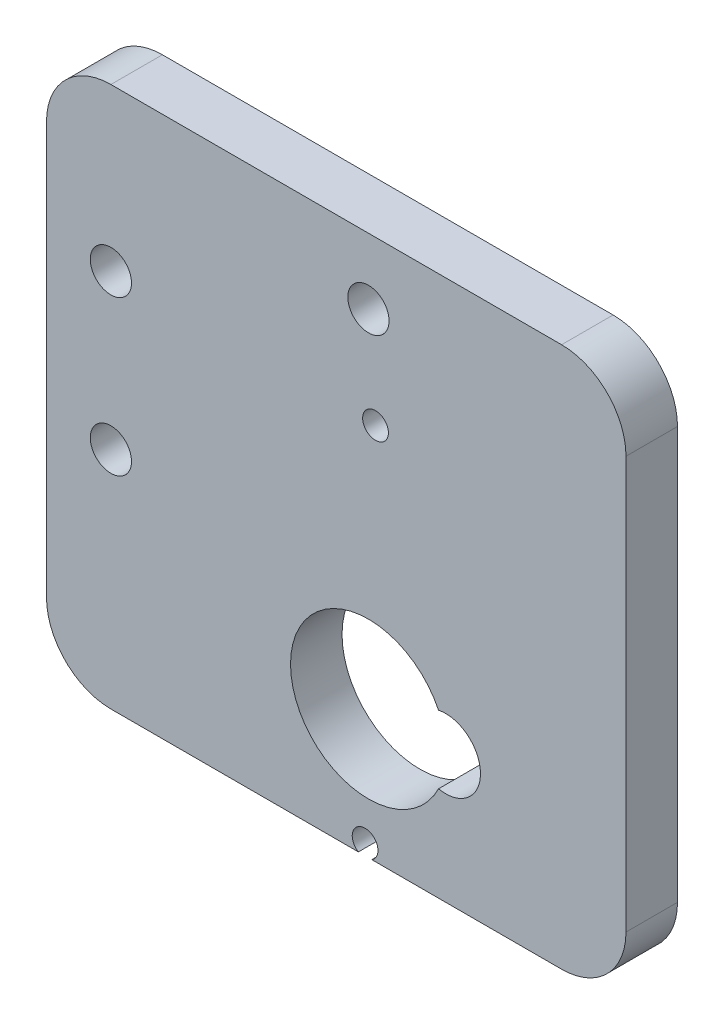
from build123d import *

# Parameters (mm, degrees)
SKETCH1_R           = 1.6
BOSS_EXTRUDE1_DEPTH = 4
FILLET1_R           = 5


with BuildPart() as part:
    # Sketch1 → Boss-Extrude1 (new body)
    with BuildSketch(Plane.XY):
        with BuildLine():
            Line((20, 32), (-25, 32))
            Line((-25, 32), (-25, -10))
            Line((-25, -10), (-0.78093138, -10))
            ThreePointArc((-0.78093138, -10), (-0.832904243, -9.966038414), (-0.882669446, -9.928917093))
            ThreePointArc((-0.882669446, -9.928917093), (-0.231731966, -8.146704874), (0.316845382, -9.963037138))
            ThreePointArc((0.316845382, -9.963037138), (0.289034097, -9.981991883), (0.260600707, -10))
            Line((0.260600707, -10), (20, -10))
            Line((20, -10), (20, 32))
        make_face()
        with Locations((-20, 7.45)):
            Circle(SKETCH1_R, mode=Mode.SUBTRACT)
        with BuildLine():
            ThreePointArc((5.442708333, -2.641860329), (-6.05, 0), (5.442708333, 2.641860329))
            ThreePointArc((5.442708333, 2.641860329), (8.7, 0), (5.442708333, -2.641860329))
        make_face(mode=Mode.SUBTRACT)
        with Locations((-20, 19.45)):
            Circle(SKETCH1_R, mode=Mode.SUBTRACT)
        with BuildLine():
            ThreePointArc((1.25114395, 18.628974283), (-0.217290022, 18.701098604), (-0.026825007, 20.158913176))
            ThreePointArc((-0.026825007, 20.158913176), (0.578619081, 20.341772292), (1.172689821, 20.124793131))
            ThreePointArc((1.172689821, 20.124793131), (1.548813096, 19.39455356), (1.25114395, 18.628974283))
        make_face(mode=Mode.SUBTRACT)
        with Locations((0, 26.9)):
            Circle(SKETCH1_R, mode=Mode.SUBTRACT)
    extrude(amount=BOSS_EXTRUDE1_DEPTH)

    # Fillet1
    fillet1_edges = [part.edges().sort_by_distance(p)[0] for p in [
        (-25, -10, 2),
        (-25, 32, 2),
        (20, 32, 2),
        (20, -10, 2),
    ]]
    fillet(fillet1_edges, radius=FILLET1_R)


solid = part.part
